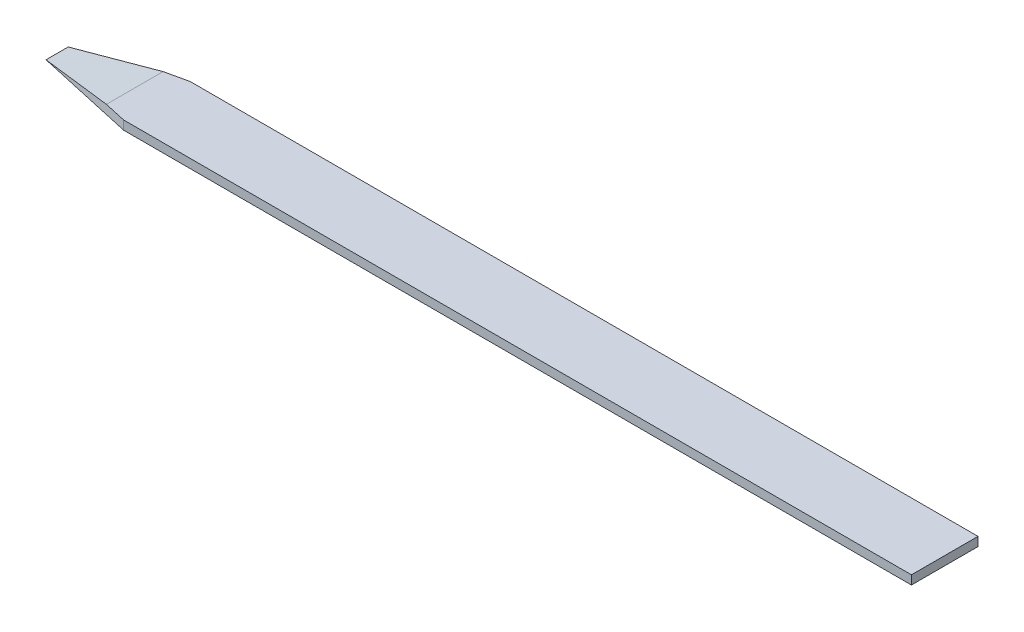
from build123d import *

# Parameters (mm, degrees)
BOSS_EXTRUDE1_DEPTH = 0.08
CUT_EXTRUDE3_DEPTH  = 9.022867318
CUT_EXTRUDE4_DEPTH  = 8.325052901


with BuildPart() as part:
    # Sketch1 → Boss-Extrude1 (new body)
    with BuildSketch(Plane(origin=(0, 0, 0), x_dir=(1, 0, 0), z_dir=(0, 1, 0))):
        Polygon((0, -0.25), (0, 0.35), (-4, 0.35), (-8, 0.35), (-8, -0.25), (-4, -0.25), align=None)
    extrude(amount=BOSS_EXTRUDE1_DEPTH)

    # Sketch5 → Cut-Extrude3 (cut, through all)
    with BuildSketch(Plane.XY.offset(0.25)):
        Polygon((-8, 0), (-8, 0.08), (-7.3, 0.08), align=None)
    extrude(amount=-CUT_EXTRUDE3_DEPTH, mode=Mode.SUBTRACT)

    # 3DSketch1 → Cut-Extrude4 (cut, through all)
    with BuildSketch(Plane(origin=(-7.3, 0.08, -0.35), x_dir=(-0.7592566023652966, 0, 0.6507913734559685), z_dir=(0, 1, 0))):
        Polygon((0.238623504, 0.585712236), (0.921954446, 0), (0.791796171, -0.15185132), align=None)
        Polygon((-0.15185132, 0.130158275), (0.531479622, -0.455553961), (0.661637896, -0.303702641), align=None)
    extrude(amount=-CUT_EXTRUDE4_DEPTH, mode=Mode.SUBTRACT)


solid = part.part
